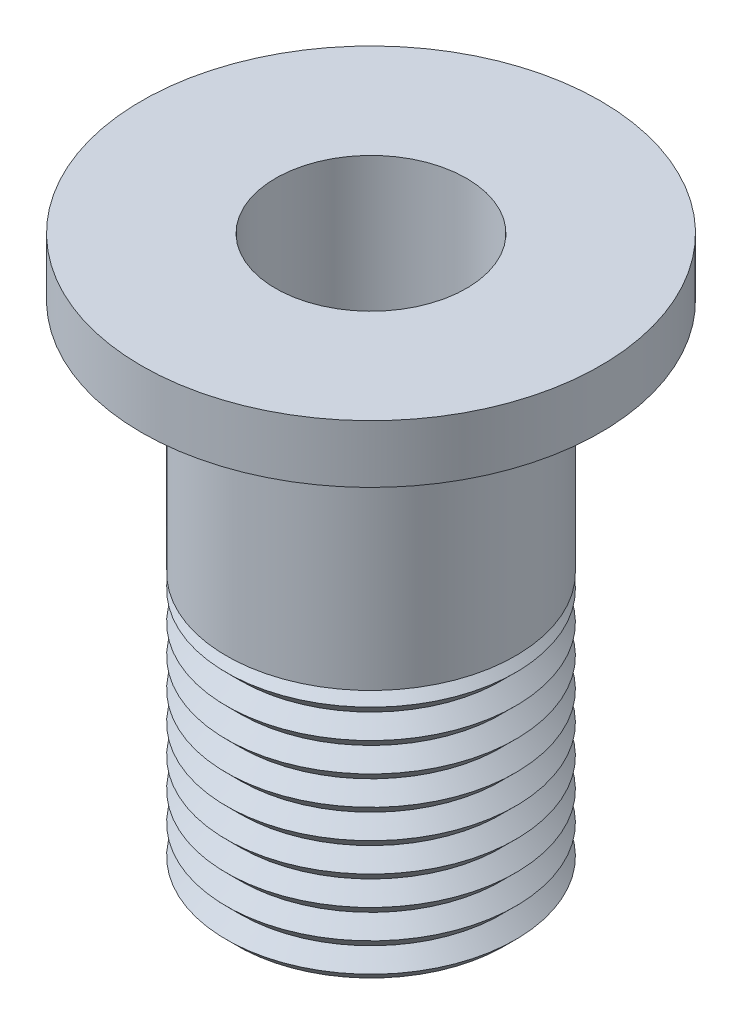
from build123d import *


with BuildPart() as part:
    # Sketch1 → Revolve1 (revolve)
    with BuildSketch(Plane.XY):
        Polygon((3.302, 0), (3.302, 19.05), (7.9375, 19.05), (7.9375, 17.05), (5, 17.05), (5, 8.89), (4.5, 8.89), (5, 8.39), (4.5, 7.89), (5, 7.39), (4.5, 6.89), (5, 6.39), (4.5, 5.89), (5, 5.39), (4.5, 4.89), (5, 4.39), (4.5, 3.89), (5, 3.39), (4.5, 2.89), (5, 2.39), (4.5, 1.89), (5, 1.39), (4.5, 0.89), (5, 0.39), (4.61, 0), align=None)
    revolve(axis=Axis((0, 0, 0), (0, 1, 0)))


solid = part.part
